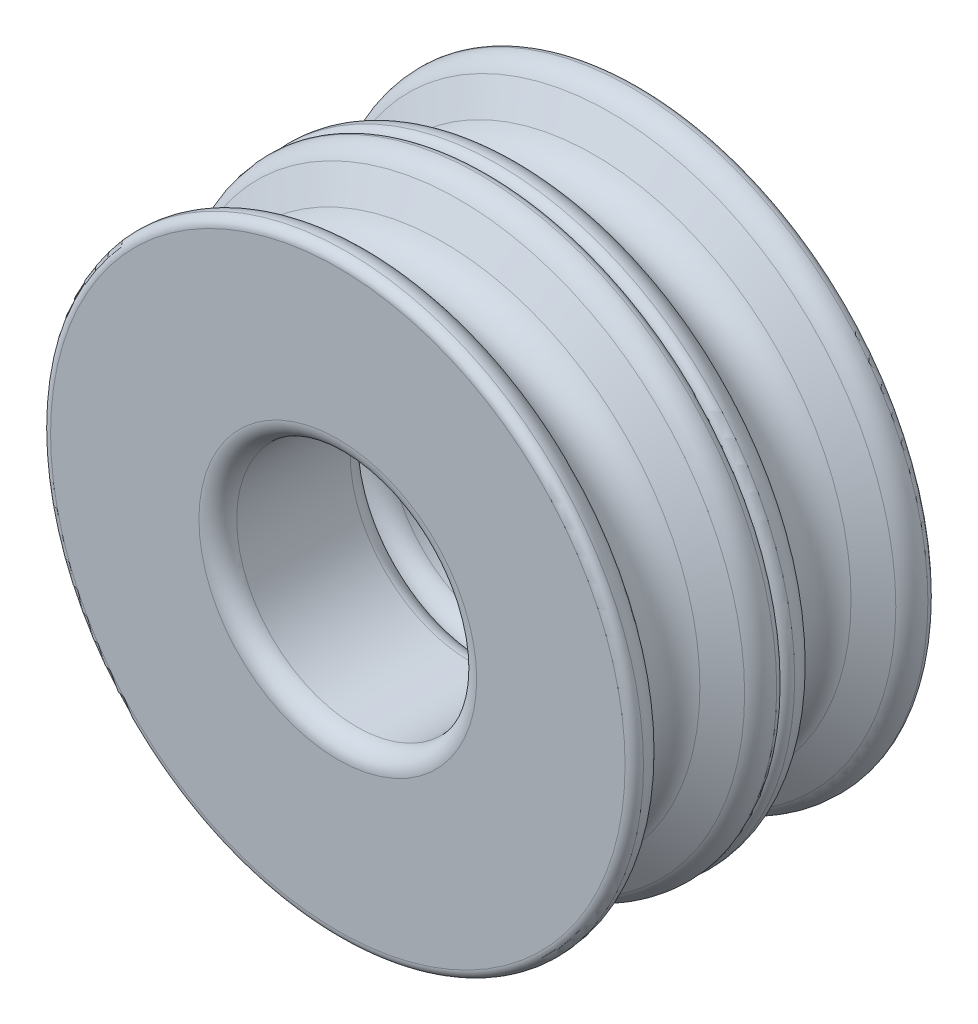
from build123d import *

# Parameters (mm, degrees)
SKETCH4_R          = 6.35
CUT_EXTRUDE1_DEPTH = 10
FILLET1_R          = 1


with BuildPart() as part:
    # Sketch1 → Revolve1 (revolve)
    with BuildSketch(Plane(origin=(0, 0, 0), x_dir=(0, 0, -1), z_dir=(1, 0, 0))):
        with BuildLine():
            Line((-4, 0), (-4, 15.200626476))
            ThreePointArc((-4, 15.200626476), (-3.86229189, 15.54521984), (-3.525021653, 15.7))
            ThreePointArc((-3.525021653, 15.7), (-2.891169071, 15.555426146), (-2.425739201, 15.101503541))
            Line((-2.425739201, 15.101503541), (-1.558845727, 13.6))
            ThreePointArc((-1.558845727, 13.6), (0, 12.7), (1.558845727, 13.6))
            Line((1.558845727, 13.6), (2.425739201, 15.101503541))
            ThreePointArc((2.425739201, 15.101503541), (2.891169071, 15.555426146), (3.525021653, 15.7))
            ThreePointArc((3.525021653, 15.7), (3.86229189, 15.54521984), (4, 15.200626476))
            Line((4, 15.200626476), (4, 0))
            Line((4, 0), (-4, 0))
        make_face()
    revolve(axis=Axis((0, 0, 0), (0, 0, 1)))

    # Sketch4 → Cut-Extrude1 (cut)
    with BuildSketch(Plane(origin=(0, 0, -4), x_dir=(-1, 0, 0), z_dir=(0, 0, -1))):
        Circle(SKETCH4_R)
    extrude(amount=-CUT_EXTRUDE1_DEPTH, mode=Mode.SUBTRACT)

    # Fillet1
    fillet1_edges = [part.edges().sort_by_distance(p)[0] for p in [
        (6.35, 0, 4),
        (6.35, 0, -4),
    ]]
    fillet(fillet1_edges, radius=FILLET1_R)

    # Mirror1: part across plane


with BuildPart() as part_1:
    add(part.part)
    add(part.part.mirror(Plane.XY.offset(4)))


solid = part_1.part
